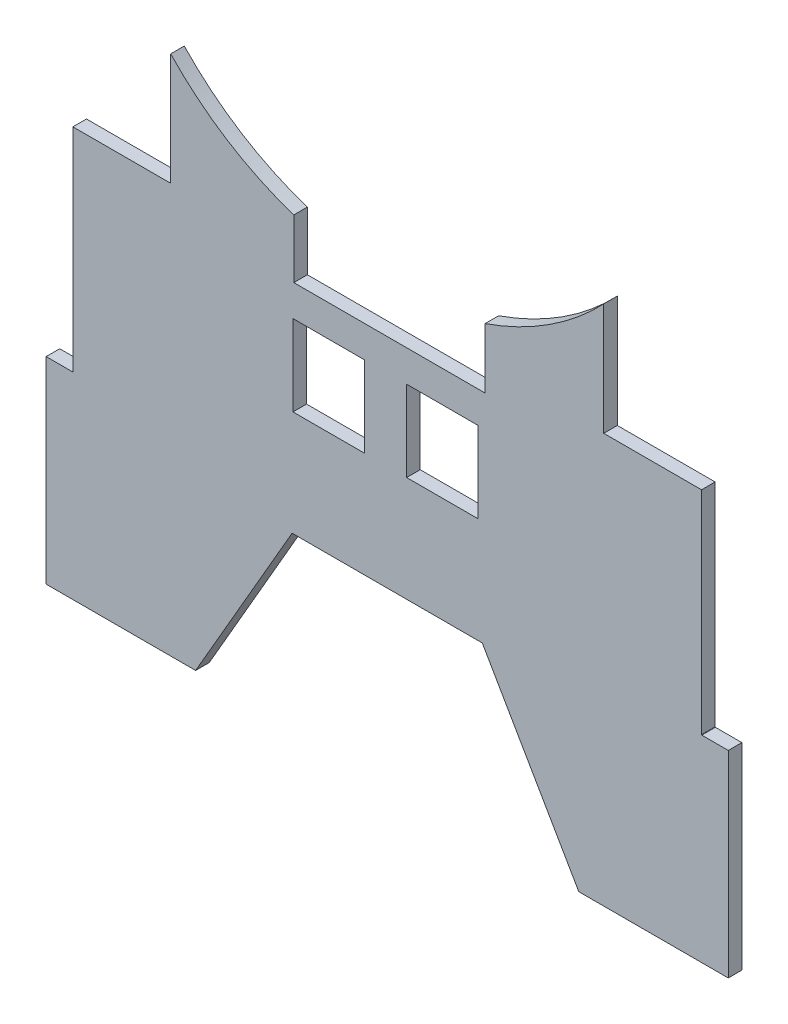
from build123d import *

# Parameters (mm, degrees)
BOSS_EXTRUDE1_DEPTH = 5
SKETCH2_W           = 26.358753283
SKETCH2_H           = 29.759882739
CUT_EXTRUDE1_DEPTH  = 5
SKETCH3_W           = 34.735720487
SKETCH3_H           = 8.029761026
BOSS_EXTRUDE2_DEPTH = 5
SKETCH4_W           = 54.614047871
SKETCH4_H           = 63
SKETCH4_W_2         = 55.31958059
CUT_EXTRUDE2_DEPTH  = 10


with BuildPart() as part:
    # Sketch1 → Boss-Extrude1 (new body)
    with BuildSketch(Plane.XY):
        with BuildLine():
            Line((-91.993742522, 102.725612705), (-126.729463009, 102.725612705))
            Line((-126.729463009, 102.725612705), (-126.746200519, 82.983777967))
            Line((-126.746200519, 82.983777967), (-126.751305113, 69.550155563))
            Line((-126.751305113, 69.550155563), (-126.751615017, 54.928897922))
            Line((-126.751615017, 54.928897922), (-116.909086823, 54.928897922))
            Line((-116.909086823, 54.928897922), (-116.909086823, -30.41815046))
            Line((-116.909086823, -30.41815046), (-126.752882712, -30.41815046))
            Line((-126.752882712, -30.41815046), (-126.752882712, -102.974632312))
            Line((-126.752882712, -102.974632312), (-71.719920422, -102.974632312))
            Line((-71.719920422, -102.974632312), (-36.199181634, -41.450908009))
            Line((-36.199181634, -41.450908009), (33.804891756, -41.450908009))
            Line((33.804891756, -41.450908009), (69.325630544, -102.974632312))
            Line((69.325630544, -102.974632312), (124.358592834, -102.974632312))
            Line((124.358592834, -102.974632312), (124.358592834, -30.41815046))
            Line((124.358592834, -30.41815046), (114.641773971, -30.41815046))
            ThreePointArc((114.641773971, -30.41815046), (114.551987655, -30.38095975), (114.514796945, -30.291173434))
            Line((114.514796945, -30.291173434), (114.514796945, 54.801920897))
            ThreePointArc((114.514796945, 54.801920897), (114.551987655, 54.891707213), (114.641773971, 54.928897922))
            Line((114.641773971, 54.928897922), (124.357325139, 54.928897922))
            Line((124.357325139, 54.928897922), (124.357015448, 69.54009331))
            Line((124.357015448, 69.54009331), (124.351902115, 82.993834667))
            Line((124.351902115, 82.993834667), (124.335173131, 102.725612705))
            Line((124.335173131, 102.725612705), (89.599452644, 102.725612705))
            ThreePointArc((89.599452644, 102.725612705), (65.571107836, 77.403597365), (34.818671263, 60.885320824))
            Line((34.818671263, 60.885320824), (34.818671263, 38.755373731))
            Line((34.818671263, 38.755373731), (-35.581655871, 38.755373731))
            Line((-35.581655871, 38.755373731), (-35.581655871, 60.334309069))
            ThreePointArc((-35.581655871, 60.334309069), (-67.279163206, 76.883706742), (-91.993742522, 102.725612705))
        make_face()
    extrude(amount=BOSS_EXTRUDE1_DEPTH)

    # Sketch2 → Cut-Extrude1 (cut)
    with BuildSketch(Plane.XY.offset(5)):
        with Locations((19.127528046, 12.255373732)):
            Rectangle(SKETCH2_W, SKETCH2_H)
        with Locations((-22.712961142, 12.255373732)):
            Rectangle(SKETCH2_W, SKETCH2_H)
    extrude(amount=-CUT_EXTRUDE1_DEPTH, mode=Mode.SUBTRACT)

    # Sketch3 → Boss-Extrude2 (add)
    with BuildSketch(Plane.XY.offset(5)):
        with Locations((-109.361602766, 106.740493218)):
            Rectangle(SKETCH3_W, SKETCH3_H)
        with Locations((106.967312888, 106.740493218)):
            Rectangle(SKETCH3_W, SKETCH3_H)
    extrude(amount=-BOSS_EXTRUDE2_DEPTH)

    # Sketch4 → Cut-Extrude2 (cut)
    with BuildSketch(Plane.XY.offset(5)):
        with Locations((105.82182088, 79.255373731)):
            Rectangle(SKETCH4_W, SKETCH4_H)
        with Locations((-108.568877118, 79.255373731)):
            Rectangle(SKETCH4_W_2, SKETCH4_H)
    extrude(amount=-CUT_EXTRUDE2_DEPTH, mode=Mode.SUBTRACT)


solid = part.part
